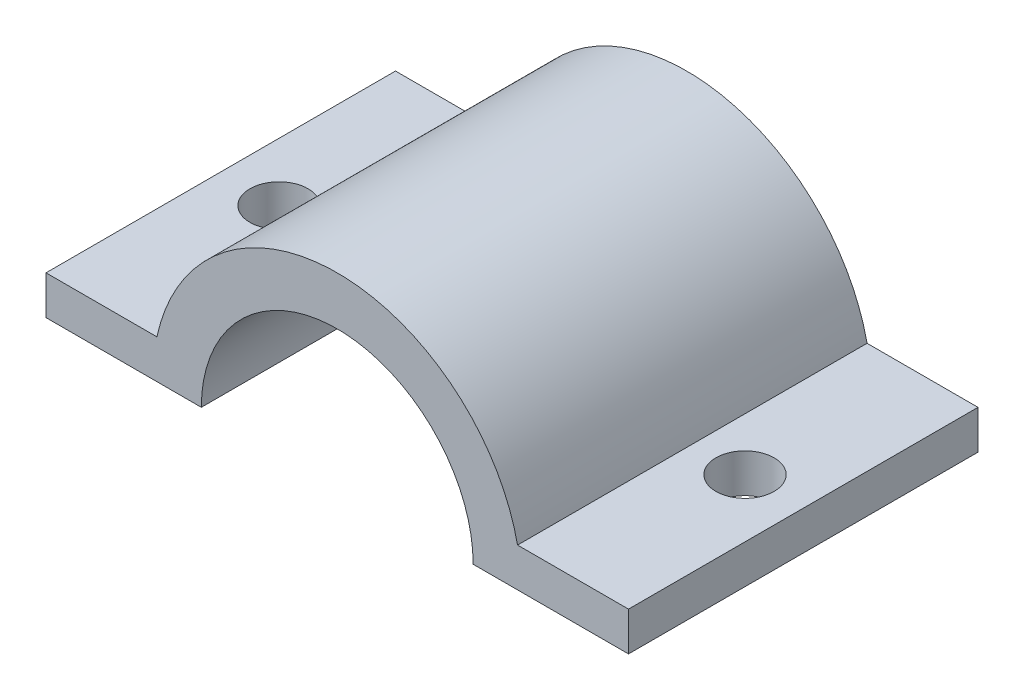
from build123d import *

# Parameters (mm, degrees)
RESSALTO_EXTRUS_O1_DEPTH = 18
ESBO_O2_R                = 1.5
CORTE_EXTRUS_O1_DEPTH    = 17


with BuildPart() as part:
    # Esboço1 → Ressalto-extrusão1 (new body)
    with BuildSketch(Plane.XY):
        with BuildLine():
            Line((10.087087811, 2), (15.8, 2))
            Line((15.8, 2), (15.8, 0))
            Line((15.8, 0), (7.8, 0))
            ThreePointArc((7.8, 0), (0.8, 7), (-6.2, 0))
            Line((-6.2, 0), (-14.2, 0))
            Line((-14.2, 0), (-14.2, 2))
            Line((-14.2, 2), (-8.487087811, 2))
            ThreePointArc((-8.487087811, 2), (0.8, 9.5), (10.087087811, 2))
        make_face()
    extrude(amount=RESSALTO_EXTRUS_O1_DEPTH)

    # Esboço2 → Corte-extrusão1 (cut)
    with BuildSketch(Plane(origin=(0, 2, 0), x_dir=(1, 0, 0), z_dir=(0, 1, 0))):
        with Locations((12.8, -9)):
            Circle(ESBO_O2_R)
        with Locations((-11.2, -9)):
            Circle(ESBO_O2_R)
    extrude(amount=-CORTE_EXTRUS_O1_DEPTH, mode=Mode.SUBTRACT)


solid = part.part
